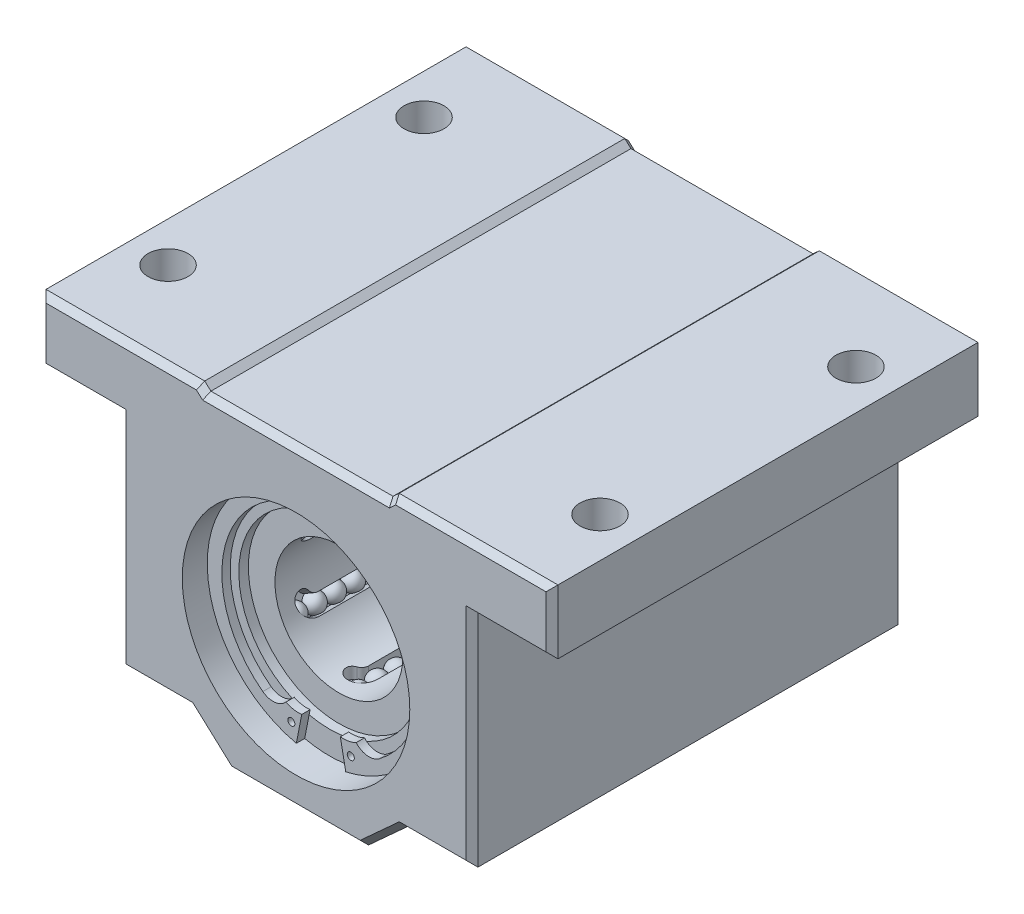
from build123d import *

# Parameters (mm, degrees)
EXTRUDE1_DEPTH          = 21.43125
SKETCH2_R               = 11.288888889
CUT_EXTRUDE1_DEPTH      = 3.31075862
SKETCH3_R               = 0.352777778
EXTRUDE2_DEPTH          = 0.827689654
SKETCH4_R               = 8.98525
CUT_EXTRUDE2_DEPTH      = 0.945931034
SKETCH5_R               = 6.35
CUT_EXTRUDE3_DEPTH      = 49.862912495
CUT_EXTRUDE4_REACH      = 39.542
CUT_EXTRUDE4_END_RADIUS = 7.478888889
CIRPATTERN1_COUNT       = 6
LPATTERN1_COUNT         = 9
LPATTERN1_PITCH         = 1.905
CIRPATTERN2_COUNT       = 6
CHAMFER1_SIZE           = 0.591206894
SKETCH13_R              = 1.984375
CUT_EXTRUDE6_DEPTH      = 6.35


with BuildPart() as part:
    # Sketch1 → Extrude1 (new, symmetric)
    with BuildSketch(Plane.XY):
        Polygon((-25.4, 15.875), (-9.652, 15.875), (-9.03605, 15.310555556), (9.03605, 15.310555556), (9.652, 15.875), (25.4, 15.875), (25.4, 9.525), (17.4625, 9.525), (17.4625, -12.347222222), (10.4775, -12.347222222), (6.604608895, -15.875), (-6.604608895, -15.875), (-10.4775, -12.347222222), (-17.4625, -12.347222222), (-17.4625, 9.525), (-25.4, 9.525), align=None)
    extrude(amount=EXTRUDE1_DEPTH, both=True)

    # Sketch2 → Cut-Extrude1 (cut)
    with BuildSketch(Plane.XY.offset(21.43125)):
        with Locations((0, -1.5875)):
            Circle(SKETCH2_R)
    cut_extrude1 = extrude(amount=-CUT_EXTRUDE1_DEPTH, mode=Mode.SUBTRACT)

    # Sketch3 → Extrude2 (add)
    with BuildSketch(Plane.XY.offset(18.12049138)):
        with BuildLine():
            Line((-1.91681812, -9.861174357), (-2.450589961, -12.607192427))
            ThreePointArc((-2.450589961, -12.607192427), (0, 9.701388889), (2.450589961, -12.607192427))
            Line((2.450589961, -12.607192427), (1.91681812, -9.861174357))
            ThreePointArc((1.91681812, -9.861174357), (2.721690888, -9.833278855), (3.485913703, -9.579188668))
            ThreePointArc((3.485913703, -9.579188668), (4.584638215, -10.150633104), (5.778499999, -9.821333333))
            ThreePointArc((5.778499999, -9.821333333), (9.370152648, 1.368526587), (0, 8.461704518))
            ThreePointArc((0, 8.461704518), (-9.370152648, 1.368526587), (-5.778499999, -9.821333333))
            ThreePointArc((-5.778499999, -9.821333333), (-4.584638215, -10.150633104), (-3.485913703, -9.579188668))
            ThreePointArc((-3.485913703, -9.579188668), (-2.721690888, -9.833278855), (-1.91681812, -9.861174357))
        make_face()
        with Locations((-2.951219351, -11.014100562)):
            Circle(SKETCH3_R, mode=Mode.SUBTRACT)
        with Locations(Location((2.951219351, -11.014100562, 0), (0, 0, 180))):
            Circle(SKETCH3_R, mode=Mode.SUBTRACT)
    extrude2 = extrude(amount=EXTRUDE2_DEPTH)

    # Sketch4 → Cut-Extrude2 (cut)
    with BuildSketch(Plane.XY.offset(18.12049138)):
        with Locations((0, -1.5875)):
            Circle(SKETCH4_R)
    cut_extrude2 = extrude(amount=-CUT_EXTRUDE2_DEPTH, mode=Mode.SUBTRACT)

    # Mirror1: Cut-Extrude1, Extrude2, Cut-Extrude2 across plane
    add(cut_extrude1.mirror(Plane.XY), mode=Mode.SUBTRACT)
    add(extrude2.mirror(Plane.XY))
    add(cut_extrude2.mirror(Plane.XY), mode=Mode.SUBTRACT)

    # Sketch5 → Cut-Extrude3 (cut, through all)
    with BuildSketch(Plane.XY.offset(17.174560346)):
        with Locations((0, -1.5875)):
            Circle(SKETCH5_R)
    extrude(amount=-CUT_EXTRUDE3_DEPTH, mode=Mode.SUBTRACT)

    # Cut-Extrude4: up to this cylinder (the profile starts inside it)
    cut_extrude4_end = Plane(origin=(0, -1.5875, 0), z_dir=(0, 0, 1)) * Cylinder(CUT_EXTRUDE4_END_RADIUS, 95.041777778, mode=Mode.PRIVATE)
    # Sketch8 → Cut-Extrude4 (cut, up to the surface)
    with BuildSketch(Plane(origin=(0, -1.5875, 0), x_dir=(-1, 0, 0), z_dir=(0, 1, 0)), mode=Mode.PRIVATE) as cut_extrude4_sk1:
        with BuildLine():
            Line((-0.803275, -14.041163793), (-0.803275, 14.041163793))
            ThreePointArc((-0.803275, 14.041163793), (-0.332727399, 15.177166193), (0.803275, 15.647713793))
            ThreePointArc((0.803275, 15.647713793), (1.576603655, 15.061725508), (1.221647396, 14.158716354))
            ThreePointArc((1.221647396, 14.158716354), (0.915018646, 13.840736557), (0.803275, 13.413365876))
            Line((0.803275, 13.413365876), (0.803275, -13.413365876))
            ThreePointArc((0.803275, -13.413365876), (0.915018646, -13.840736557), (1.221647396, -14.158716354))
            ThreePointArc((1.221647396, -14.158716354), (1.576603655, -15.061725508), (0.803275, -15.647713793))
            ThreePointArc((0.803275, -15.647713793), (-0.332727399, -15.177166193), (-0.803275, -14.041163793))
        make_face()
    cut_extrude4_tool1 = extrude(cut_extrude4_sk1.sketch, amount=-CUT_EXTRUDE4_REACH, mode=Mode.PRIVATE) & cut_extrude4_end
    cut_extrude4 = cut_extrude4_tool1.solids().sort_by_distance((-0.056828, -1.5875, 0))[0]
    add(cut_extrude4, mode=Mode.SUBTRACT)

    # CirPattern1: Cut-Extrude4 ×6 about axis
    cirpattern1_axis = Axis((0, -1.5875, 0), (0, 0, 1))
    for i in range(1, CIRPATTERN1_COUNT):
        add(cut_extrude4.rotate(cirpattern1_axis, i * 360 / CIRPATTERN1_COUNT), mode=Mode.SUBTRACT)

    # Sketch10 → Revolve2 (revolve)
    with BuildSketch(Plane.XY):
        with BuildLine():
            Line((-0.948795833, -8.886295833), (0.948795833, -8.886295833))
            ThreePointArc((0.948795833, -8.886295833), (0, -7.9375), (-0.948795833, -8.886295833))
        make_face()
    revolve2 = revolve(axis=Axis((-0.948795833, -8.886295833, 0), (1, 0, 0)))

    # LPattern1: Revolve2 ×9
    with Locations(*[(0, 0, i * LPATTERN1_PITCH) for i in range(1, LPATTERN1_COUNT)]):
        add(revolve2)

    # Mirror2: Revolve2 across plane
    add(revolve2.mirror(Plane.XY))

    # Mirror2 copy 1 sketch → Mirror2 copy 1 (revolve)
    with BuildSketch(Plane(origin=(0, 0, -1.905), x_dir=(1, 0, 0), z_dir=(0, 0, -1))):
        with BuildLine():
            Line((-0.948795833, 8.886295833), (0.948795833, 8.886295833))
            ThreePointArc((0.948795833, 8.886295833), (0, 7.9375), (-0.948795833, 8.886295833))
        make_face()
    revolve(axis=Axis((-0.948795833, -8.886295833, -1.905), (-1, 0, 0)))

    # Mirror2 copy 2 sketch → Mirror2 copy 2 (revolve)
    with BuildSketch(Plane(origin=(0, 0, -3.81), x_dir=(1, 0, 0), z_dir=(0, 0, -1))):
        with BuildLine():
            Line((-0.948795833, 8.886295833), (0.948795833, 8.886295833))
            ThreePointArc((0.948795833, 8.886295833), (0, 7.9375), (-0.948795833, 8.886295833))
        make_face()
    revolve(axis=Axis((-0.948795833, -8.886295833, -3.81), (-1, 0, 0)))

    # Mirror2 copy 3 sketch → Mirror2 copy 3 (revolve)
    with BuildSketch(Plane(origin=(0, 0, -5.715), x_dir=(1, 0, 0), z_dir=(0, 0, -1))):
        with BuildLine():
            Line((-0.948795833, 8.886295833), (0.948795833, 8.886295833))
            ThreePointArc((0.948795833, 8.886295833), (0, 7.9375), (-0.948795833, 8.886295833))
        make_face()
    revolve(axis=Axis((-0.948795833, -8.886295833, -5.715), (-1, 0, 0)))

    # Mirror2 copy 4 sketch → Mirror2 copy 4 (revolve)
    with BuildSketch(Plane(origin=(0, 0, -7.62), x_dir=(1, 0, 0), z_dir=(0, 0, -1))):
        with BuildLine():
            Line((-0.948795833, 8.886295833), (0.948795833, 8.886295833))
            ThreePointArc((0.948795833, 8.886295833), (0, 7.9375), (-0.948795833, 8.886295833))
        make_face()
    revolve(axis=Axis((-0.948795833, -8.886295833, -7.62), (-1, 0, 0)))

    # Mirror2 copy 5 sketch → Mirror2 copy 5 (revolve)
    with BuildSketch(Plane(origin=(0, 0, -9.525), x_dir=(1, 0, 0), z_dir=(0, 0, -1))):
        with BuildLine():
            Line((-0.948795833, 8.886295833), (0.948795833, 8.886295833))
            ThreePointArc((0.948795833, 8.886295833), (0, 7.9375), (-0.948795833, 8.886295833))
        make_face()
    revolve(axis=Axis((-0.948795833, -8.886295833, -9.525), (-1, 0, 0)))

    # Mirror2 copy 6 sketch → Mirror2 copy 6 (revolve)
    with BuildSketch(Plane(origin=(0, 0, -11.43), x_dir=(1, 0, 0), z_dir=(0, 0, -1))):
        with BuildLine():
            Line((-0.948795833, 8.886295833), (0.948795833, 8.886295833))
            ThreePointArc((0.948795833, 8.886295833), (0, 7.9375), (-0.948795833, 8.886295833))
        make_face()
    revolve(axis=Axis((-0.948795833, -8.886295833, -11.43), (-1, 0, 0)))

    # Mirror2 copy 7 sketch → Mirror2 copy 7 (revolve)
    with BuildSketch(Plane(origin=(0, 0, -13.335), x_dir=(1, 0, 0), z_dir=(0, 0, -1))):
        with BuildLine():
            Line((-0.948795833, 8.886295833), (0.948795833, 8.886295833))
            ThreePointArc((0.948795833, 8.886295833), (0, 7.9375), (-0.948795833, 8.886295833))
        make_face()
    revolve(axis=Axis((-0.948795833, -8.886295833, -13.335), (-1, 0, 0)))

    # Mirror2 copy 8 sketch → Mirror2 copy 8 (revolve)
    with BuildSketch(Plane(origin=(0, 0, -15.24), x_dir=(1, 0, 0), z_dir=(0, 0, -1))):
        with BuildLine():
            Line((-0.948795833, 8.886295833), (0.948795833, 8.886295833))
            ThreePointArc((0.948795833, 8.886295833), (0, 7.9375), (-0.948795833, 8.886295833))
        make_face()
    revolve(axis=Axis((-0.948795833, -8.886295833, -15.24), (-1, 0, 0)))

    # CirPattern2: Revolve2 ×6 about axis
    cirpattern2_axis = Axis((0, -1.5875, 0), (0, 0, 1))
    for i in range(1, CIRPATTERN2_COUNT):
        add(revolve2.rotate(cirpattern2_axis, i * 360 / CIRPATTERN2_COUNT))

    # CirPattern2 copy 1 sketch → CirPattern2 copy 1 (revolve)
    with BuildSketch(Plane(origin=(-1.374815329, -0.79375, 1.905), x_dir=(0.5000000000000001, 0.8660254037844386, 0), z_dir=(0, 0, 1))):
        with BuildLine():
            Line((-0.948795833, -8.886295833), (0.948795833, -8.886295833))
            ThreePointArc((0.948795833, -8.886295833), (0, -7.9375), (-0.948795833, -8.886295833))
        make_face()
    revolve(axis=Axis((5.846544692, -6.058579211, 1.905), (0.5000000000000001, 0.8660254037844386, 0)))

    # CirPattern2 copy 2 sketch → CirPattern2 copy 2 (revolve)
    with BuildSketch(Plane(origin=(-1.374815329, -2.38125, 1.905), x_dir=(-0.4999999999999998, 0.8660254037844387, 0), z_dir=(0, 0, 1))):
        with BuildLine():
            Line((-0.948795833, -8.886295833), (0.948795833, -8.886295833))
            ThreePointArc((0.948795833, -8.886295833), (0, -7.9375), (-0.948795833, -8.886295833))
        make_face()
    revolve(axis=Axis((6.795340526, 1.240216622, 1.905), (-0.4999999999999998, 0.8660254037844387, 0)))

    # CirPattern2 copy 3 sketch → CirPattern2 copy 3 (revolve)
    with BuildSketch(Plane(origin=(0, -3.175, 1.905), x_dir=(-1, 0, 0), z_dir=(0, 0, 1))):
        with BuildLine():
            Line((-0.948795833, -8.886295833), (0.948795833, -8.886295833))
            ThreePointArc((0.948795833, -8.886295833), (0, -7.9375), (-0.948795833, -8.886295833))
        make_face()
    revolve(axis=Axis((0.948795833, 5.711295833, 1.905), (-1, 0, 0)))

    # CirPattern2 copy 4 sketch → CirPattern2 copy 4 (revolve)
    with BuildSketch(Plane(origin=(1.374815329, -2.38125, 1.905), x_dir=(-0.5000000000000004, -0.8660254037844384, 0), z_dir=(0, 0, 1))):
        with BuildLine():
            Line((-0.948795833, -8.886295833), (0.948795833, -8.886295833))
            ThreePointArc((0.948795833, -8.886295833), (0, -7.9375), (-0.948795833, -8.886295833))
        make_face()
    revolve(axis=Axis((-5.846544692, 2.883579211, 1.905), (-0.5000000000000004, -0.8660254037844384, 0)))

    # CirPattern2 copy 5 sketch → CirPattern2 copy 5 (revolve)
    with BuildSketch(Plane(origin=(1.374815329, -0.79375, 1.905), x_dir=(0.5000000000000001, -0.8660254037844386, 0), z_dir=(0, 0, 1))):
        with BuildLine():
            Line((-0.948795833, -8.886295833), (0.948795833, -8.886295833))
            ThreePointArc((0.948795833, -8.886295833), (0, -7.9375), (-0.948795833, -8.886295833))
        make_face()
    revolve(axis=Axis((-6.795340526, -4.415216622, 1.905), (0.5000000000000001, -0.8660254037844386, 0)))

    # CirPattern2 copy 6 sketch → CirPattern2 copy 6 (revolve)
    with BuildSketch(Plane(origin=(-1.374815329, -0.79375, 3.81), x_dir=(0.5000000000000001, 0.8660254037844386, 0), z_dir=(0, 0, 1))):
        with BuildLine():
            Line((-0.948795833, -8.886295833), (0.948795833, -8.886295833))
            ThreePointArc((0.948795833, -8.886295833), (0, -7.9375), (-0.948795833, -8.886295833))
        make_face()
    revolve(axis=Axis((5.846544692, -6.058579211, 3.81), (0.5000000000000001, 0.8660254037844386, 0)))

    # CirPattern2 copy 7 sketch → CirPattern2 copy 7 (revolve)
    with BuildSketch(Plane(origin=(-1.374815329, -2.38125, 3.81), x_dir=(-0.4999999999999998, 0.8660254037844387, 0), z_dir=(0, 0, 1))):
        with BuildLine():
            Line((-0.948795833, -8.886295833), (0.948795833, -8.886295833))
            ThreePointArc((0.948795833, -8.886295833), (0, -7.9375), (-0.948795833, -8.886295833))
        make_face()
    revolve(axis=Axis((6.795340526, 1.240216622, 3.81), (-0.4999999999999998, 0.8660254037844387, 0)))

    # CirPattern2 copy 8 sketch → CirPattern2 copy 8 (revolve)
    with BuildSketch(Plane(origin=(0, -3.175, 3.81), x_dir=(-1, 0, 0), z_dir=(0, 0, 1))):
        with BuildLine():
            Line((-0.948795833, -8.886295833), (0.948795833, -8.886295833))
            ThreePointArc((0.948795833, -8.886295833), (0, -7.9375), (-0.948795833, -8.886295833))
        make_face()
    revolve(axis=Axis((0.948795833, 5.711295833, 3.81), (-1, 0, 0)))

    # CirPattern2 copy 9 sketch → CirPattern2 copy 9 (revolve)
    with BuildSketch(Plane(origin=(1.374815329, -2.38125, 3.81), x_dir=(-0.5000000000000004, -0.8660254037844384, 0), z_dir=(0, 0, 1))):
        with BuildLine():
            Line((-0.948795833, -8.886295833), (0.948795833, -8.886295833))
            ThreePointArc((0.948795833, -8.886295833), (0, -7.9375), (-0.948795833, -8.886295833))
        make_face()
    revolve(axis=Axis((-5.846544692, 2.883579211, 3.81), (-0.5000000000000004, -0.8660254037844384, 0)))

    # CirPattern2 copy 10 sketch → CirPattern2 copy 10 (revolve)
    with BuildSketch(Plane(origin=(1.374815329, -0.79375, 3.81), x_dir=(0.5000000000000001, -0.8660254037844386, 0), z_dir=(0, 0, 1))):
        with BuildLine():
            Line((-0.948795833, -8.886295833), (0.948795833, -8.886295833))
            ThreePointArc((0.948795833, -8.886295833), (0, -7.9375), (-0.948795833, -8.886295833))
        make_face()
    revolve(axis=Axis((-6.795340526, -4.415216622, 3.81), (0.5000000000000001, -0.8660254037844386, 0)))

    # CirPattern2 copy 11 sketch → CirPattern2 copy 11 (revolve)
    with BuildSketch(Plane(origin=(-1.374815329, -0.79375, 5.715), x_dir=(0.5000000000000001, 0.8660254037844386, 0), z_dir=(0, 0, 1))):
        with BuildLine():
            Line((-0.948795833, -8.886295833), (0.948795833, -8.886295833))
            ThreePointArc((0.948795833, -8.886295833), (0, -7.9375), (-0.948795833, -8.886295833))
        make_face()
    revolve(axis=Axis((5.846544692, -6.058579211, 5.715), (0.5000000000000001, 0.8660254037844386, 0)))

    # CirPattern2 copy 12 sketch → CirPattern2 copy 12 (revolve)
    with BuildSketch(Plane(origin=(-1.374815329, -2.38125, 5.715), x_dir=(-0.4999999999999998, 0.8660254037844387, 0), z_dir=(0, 0, 1))):
        with BuildLine():
            Line((-0.948795833, -8.886295833), (0.948795833, -8.886295833))
            ThreePointArc((0.948795833, -8.886295833), (0, -7.9375), (-0.948795833, -8.886295833))
        make_face()
    revolve(axis=Axis((6.795340526, 1.240216622, 5.715), (-0.4999999999999998, 0.8660254037844387, 0)))

    # CirPattern2 copy 13 sketch → CirPattern2 copy 13 (revolve)
    with BuildSketch(Plane(origin=(0, -3.175, 5.715), x_dir=(-1, 0, 0), z_dir=(0, 0, 1))):
        with BuildLine():
            Line((-0.948795833, -8.886295833), (0.948795833, -8.886295833))
            ThreePointArc((0.948795833, -8.886295833), (0, -7.9375), (-0.948795833, -8.886295833))
        make_face()
    revolve(axis=Axis((0.948795833, 5.711295833, 5.715), (-1, 0, 0)))

    # CirPattern2 copy 14 sketch → CirPattern2 copy 14 (revolve)
    with BuildSketch(Plane(origin=(1.374815329, -2.38125, 5.715), x_dir=(-0.5000000000000004, -0.8660254037844384, 0), z_dir=(0, 0, 1))):
        with BuildLine():
            Line((-0.948795833, -8.886295833), (0.948795833, -8.886295833))
            ThreePointArc((0.948795833, -8.886295833), (0, -7.9375), (-0.948795833, -8.886295833))
        make_face()
    revolve(axis=Axis((-5.846544692, 2.883579211, 5.715), (-0.5000000000000004, -0.8660254037844384, 0)))

    # CirPattern2 copy 15 sketch → CirPattern2 copy 15 (revolve)
    with BuildSketch(Plane(origin=(1.374815329, -0.79375, 5.715), x_dir=(0.5000000000000001, -0.8660254037844386, 0), z_dir=(0, 0, 1))):
        with BuildLine():
            Line((-0.948795833, -8.886295833), (0.948795833, -8.886295833))
            ThreePointArc((0.948795833, -8.886295833), (0, -7.9375), (-0.948795833, -8.886295833))
        make_face()
    revolve(axis=Axis((-6.795340526, -4.415216622, 5.715), (0.5000000000000001, -0.8660254037844386, 0)))

    # CirPattern2 copy 16 sketch → CirPattern2 copy 16 (revolve)
    with BuildSketch(Plane(origin=(-1.374815329, -0.79375, 7.62), x_dir=(0.5000000000000001, 0.8660254037844386, 0), z_dir=(0, 0, 1))):
        with BuildLine():
            Line((-0.948795833, -8.886295833), (0.948795833, -8.886295833))
            ThreePointArc((0.948795833, -8.886295833), (0, -7.9375), (-0.948795833, -8.886295833))
        make_face()
    revolve(axis=Axis((5.846544692, -6.058579211, 7.62), (0.5000000000000001, 0.8660254037844386, 0)))

    # CirPattern2 copy 17 sketch → CirPattern2 copy 17 (revolve)
    with BuildSketch(Plane(origin=(-1.374815329, -2.38125, 7.62), x_dir=(-0.4999999999999998, 0.8660254037844387, 0), z_dir=(0, 0, 1))):
        with BuildLine():
            Line((-0.948795833, -8.886295833), (0.948795833, -8.886295833))
            ThreePointArc((0.948795833, -8.886295833), (0, -7.9375), (-0.948795833, -8.886295833))
        make_face()
    revolve(axis=Axis((6.795340526, 1.240216622, 7.62), (-0.4999999999999998, 0.8660254037844387, 0)))

    # CirPattern2 copy 18 sketch → CirPattern2 copy 18 (revolve)
    with BuildSketch(Plane(origin=(0, -3.175, 7.62), x_dir=(-1, 0, 0), z_dir=(0, 0, 1))):
        with BuildLine():
            Line((-0.948795833, -8.886295833), (0.948795833, -8.886295833))
            ThreePointArc((0.948795833, -8.886295833), (0, -7.9375), (-0.948795833, -8.886295833))
        make_face()
    revolve(axis=Axis((0.948795833, 5.711295833, 7.62), (-1, 0, 0)))

    # CirPattern2 copy 19 sketch → CirPattern2 copy 19 (revolve)
    with BuildSketch(Plane(origin=(1.374815329, -2.38125, 7.62), x_dir=(-0.5000000000000004, -0.8660254037844384, 0), z_dir=(0, 0, 1))):
        with BuildLine():
            Line((-0.948795833, -8.886295833), (0.948795833, -8.886295833))
            ThreePointArc((0.948795833, -8.886295833), (0, -7.9375), (-0.948795833, -8.886295833))
        make_face()
    revolve(axis=Axis((-5.846544692, 2.883579211, 7.62), (-0.5000000000000004, -0.8660254037844384, 0)))

    # CirPattern2 copy 20 sketch → CirPattern2 copy 20 (revolve)
    with BuildSketch(Plane(origin=(1.374815329, -0.79375, 7.62), x_dir=(0.5000000000000001, -0.8660254037844386, 0), z_dir=(0, 0, 1))):
        with BuildLine():
            Line((-0.948795833, -8.886295833), (0.948795833, -8.886295833))
            ThreePointArc((0.948795833, -8.886295833), (0, -7.9375), (-0.948795833, -8.886295833))
        make_face()
    revolve(axis=Axis((-6.795340526, -4.415216622, 7.62), (0.5000000000000001, -0.8660254037844386, 0)))

    # CirPattern2 copy 21 sketch → CirPattern2 copy 21 (revolve)
    with BuildSketch(Plane(origin=(-1.374815329, -0.79375, 9.525), x_dir=(0.5000000000000001, 0.8660254037844386, 0), z_dir=(0, 0, 1))):
        with BuildLine():
            Line((-0.948795833, -8.886295833), (0.948795833, -8.886295833))
            ThreePointArc((0.948795833, -8.886295833), (0, -7.9375), (-0.948795833, -8.886295833))
        make_face()
    revolve(axis=Axis((5.846544692, -6.058579211, 9.525), (0.5000000000000001, 0.8660254037844386, 0)))

    # CirPattern2 copy 22 sketch → CirPattern2 copy 22 (revolve)
    with BuildSketch(Plane(origin=(-1.374815329, -2.38125, 9.525), x_dir=(-0.4999999999999998, 0.8660254037844387, 0), z_dir=(0, 0, 1))):
        with BuildLine():
            Line((-0.948795833, -8.886295833), (0.948795833, -8.886295833))
            ThreePointArc((0.948795833, -8.886295833), (0, -7.9375), (-0.948795833, -8.886295833))
        make_face()
    revolve(axis=Axis((6.795340526, 1.240216622, 9.525), (-0.4999999999999998, 0.8660254037844387, 0)))

    # CirPattern2 copy 23 sketch → CirPattern2 copy 23 (revolve)
    with BuildSketch(Plane(origin=(0, -3.175, 9.525), x_dir=(-1, 0, 0), z_dir=(0, 0, 1))):
        with BuildLine():
            Line((-0.948795833, -8.886295833), (0.948795833, -8.886295833))
            ThreePointArc((0.948795833, -8.886295833), (0, -7.9375), (-0.948795833, -8.886295833))
        make_face()
    revolve(axis=Axis((0.948795833, 5.711295833, 9.525), (-1, 0, 0)))

    # CirPattern2 copy 24 sketch → CirPattern2 copy 24 (revolve)
    with BuildSketch(Plane(origin=(1.374815329, -2.38125, 9.525), x_dir=(-0.5000000000000004, -0.8660254037844384, 0), z_dir=(0, 0, 1))):
        with BuildLine():
            Line((-0.948795833, -8.886295833), (0.948795833, -8.886295833))
            ThreePointArc((0.948795833, -8.886295833), (0, -7.9375), (-0.948795833, -8.886295833))
        make_face()
    revolve(axis=Axis((-5.846544692, 2.883579211, 9.525), (-0.5000000000000004, -0.8660254037844384, 0)))

    # CirPattern2 copy 25 sketch → CirPattern2 copy 25 (revolve)
    with BuildSketch(Plane(origin=(1.374815329, -0.79375, 9.525), x_dir=(0.5000000000000001, -0.8660254037844386, 0), z_dir=(0, 0, 1))):
        with BuildLine():
            Line((-0.948795833, -8.886295833), (0.948795833, -8.886295833))
            ThreePointArc((0.948795833, -8.886295833), (0, -7.9375), (-0.948795833, -8.886295833))
        make_face()
    revolve(axis=Axis((-6.795340526, -4.415216622, 9.525), (0.5000000000000001, -0.8660254037844386, 0)))

    # CirPattern2 copy 26 sketch → CirPattern2 copy 26 (revolve)
    with BuildSketch(Plane(origin=(-1.374815329, -0.79375, 11.43), x_dir=(0.5000000000000001, 0.8660254037844386, 0), z_dir=(0, 0, 1))):
        with BuildLine():
            Line((-0.948795833, -8.886295833), (0.948795833, -8.886295833))
            ThreePointArc((0.948795833, -8.886295833), (0, -7.9375), (-0.948795833, -8.886295833))
        make_face()
    revolve(axis=Axis((5.846544692, -6.058579211, 11.43), (0.5000000000000001, 0.8660254037844386, 0)))

    # CirPattern2 copy 27 sketch → CirPattern2 copy 27 (revolve)
    with BuildSketch(Plane(origin=(-1.374815329, -2.38125, 11.43), x_dir=(-0.4999999999999998, 0.8660254037844387, 0), z_dir=(0, 0, 1))):
        with BuildLine():
            Line((-0.948795833, -8.886295833), (0.948795833, -8.886295833))
            ThreePointArc((0.948795833, -8.886295833), (0, -7.9375), (-0.948795833, -8.886295833))
        make_face()
    revolve(axis=Axis((6.795340526, 1.240216622, 11.43), (-0.4999999999999998, 0.8660254037844387, 0)))

    # CirPattern2 copy 28 sketch → CirPattern2 copy 28 (revolve)
    with BuildSketch(Plane(origin=(0, -3.175, 11.43), x_dir=(-1, 0, 0), z_dir=(0, 0, 1))):
        with BuildLine():
            Line((-0.948795833, -8.886295833), (0.948795833, -8.886295833))
            ThreePointArc((0.948795833, -8.886295833), (0, -7.9375), (-0.948795833, -8.886295833))
        make_face()
    revolve(axis=Axis((0.948795833, 5.711295833, 11.43), (-1, 0, 0)))

    # CirPattern2 copy 29 sketch → CirPattern2 copy 29 (revolve)
    with BuildSketch(Plane(origin=(1.374815329, -2.38125, 11.43), x_dir=(-0.5000000000000004, -0.8660254037844384, 0), z_dir=(0, 0, 1))):
        with BuildLine():
            Line((-0.948795833, -8.886295833), (0.948795833, -8.886295833))
            ThreePointArc((0.948795833, -8.886295833), (0, -7.9375), (-0.948795833, -8.886295833))
        make_face()
    revolve(axis=Axis((-5.846544692, 2.883579211, 11.43), (-0.5000000000000004, -0.8660254037844384, 0)))

    # CirPattern2 copy 30 sketch → CirPattern2 copy 30 (revolve)
    with BuildSketch(Plane(origin=(1.374815329, -0.79375, 11.43), x_dir=(0.5000000000000001, -0.8660254037844386, 0), z_dir=(0, 0, 1))):
        with BuildLine():
            Line((-0.948795833, -8.886295833), (0.948795833, -8.886295833))
            ThreePointArc((0.948795833, -8.886295833), (0, -7.9375), (-0.948795833, -8.886295833))
        make_face()
    revolve(axis=Axis((-6.795340526, -4.415216622, 11.43), (0.5000000000000001, -0.8660254037844386, 0)))

    # CirPattern2 copy 31 sketch → CirPattern2 copy 31 (revolve)
    with BuildSketch(Plane(origin=(-1.374815329, -0.79375, 13.335), x_dir=(0.5000000000000001, 0.8660254037844386, 0), z_dir=(0, 0, 1))):
        with BuildLine():
            Line((-0.948795833, -8.886295833), (0.948795833, -8.886295833))
            ThreePointArc((0.948795833, -8.886295833), (0, -7.9375), (-0.948795833, -8.886295833))
        make_face()
    revolve(axis=Axis((5.846544692, -6.058579211, 13.335), (0.5000000000000001, 0.8660254037844386, 0)))

    # CirPattern2 copy 32 sketch → CirPattern2 copy 32 (revolve)
    with BuildSketch(Plane(origin=(-1.374815329, -2.38125, 13.335), x_dir=(-0.4999999999999998, 0.8660254037844387, 0), z_dir=(0, 0, 1))):
        with BuildLine():
            Line((-0.948795833, -8.886295833), (0.948795833, -8.886295833))
            ThreePointArc((0.948795833, -8.886295833), (0, -7.9375), (-0.948795833, -8.886295833))
        make_face()
    revolve(axis=Axis((6.795340526, 1.240216622, 13.335), (-0.4999999999999998, 0.8660254037844387, 0)))

    # CirPattern2 copy 33 sketch → CirPattern2 copy 33 (revolve)
    with BuildSketch(Plane(origin=(0, -3.175, 13.335), x_dir=(-1, 0, 0), z_dir=(0, 0, 1))):
        with BuildLine():
            Line((-0.948795833, -8.886295833), (0.948795833, -8.886295833))
            ThreePointArc((0.948795833, -8.886295833), (0, -7.9375), (-0.948795833, -8.886295833))
        make_face()
    revolve(axis=Axis((0.948795833, 5.711295833, 13.335), (-1, 0, 0)))

    # CirPattern2 copy 34 sketch → CirPattern2 copy 34 (revolve)
    with BuildSketch(Plane(origin=(1.374815329, -2.38125, 13.335), x_dir=(-0.5000000000000004, -0.8660254037844384, 0), z_dir=(0, 0, 1))):
        with BuildLine():
            Line((-0.948795833, -8.886295833), (0.948795833, -8.886295833))
            ThreePointArc((0.948795833, -8.886295833), (0, -7.9375), (-0.948795833, -8.886295833))
        make_face()
    revolve(axis=Axis((-5.846544692, 2.883579211, 13.335), (-0.5000000000000004, -0.8660254037844384, 0)))

    # CirPattern2 copy 35 sketch → CirPattern2 copy 35 (revolve)
    with BuildSketch(Plane(origin=(1.374815329, -0.79375, 13.335), x_dir=(0.5000000000000001, -0.8660254037844386, 0), z_dir=(0, 0, 1))):
        with BuildLine():
            Line((-0.948795833, -8.886295833), (0.948795833, -8.886295833))
            ThreePointArc((0.948795833, -8.886295833), (0, -7.9375), (-0.948795833, -8.886295833))
        make_face()
    revolve(axis=Axis((-6.795340526, -4.415216622, 13.335), (0.5000000000000001, -0.8660254037844386, 0)))

    # CirPattern2 copy 36 sketch → CirPattern2 copy 36 (revolve)
    with BuildSketch(Plane(origin=(-1.374815329, -0.79375, 15.24), x_dir=(0.5000000000000001, 0.8660254037844386, 0), z_dir=(0, 0, 1))):
        with BuildLine():
            Line((-0.948795833, -8.886295833), (0.948795833, -8.886295833))
            ThreePointArc((0.948795833, -8.886295833), (0, -7.9375), (-0.948795833, -8.886295833))
        make_face()
    revolve(axis=Axis((5.846544692, -6.058579211, 15.24), (0.5000000000000001, 0.8660254037844386, 0)))

    # CirPattern2 copy 37 sketch → CirPattern2 copy 37 (revolve)
    with BuildSketch(Plane(origin=(-1.374815329, -2.38125, 15.24), x_dir=(-0.4999999999999998, 0.8660254037844387, 0), z_dir=(0, 0, 1))):
        with BuildLine():
            Line((-0.948795833, -8.886295833), (0.948795833, -8.886295833))
            ThreePointArc((0.948795833, -8.886295833), (0, -7.9375), (-0.948795833, -8.886295833))
        make_face()
    revolve(axis=Axis((6.795340526, 1.240216622, 15.24), (-0.4999999999999998, 0.8660254037844387, 0)))

    # CirPattern2 copy 38 sketch → CirPattern2 copy 38 (revolve)
    with BuildSketch(Plane(origin=(0, -3.175, 15.24), x_dir=(-1, 0, 0), z_dir=(0, 0, 1))):
        with BuildLine():
            Line((-0.948795833, -8.886295833), (0.948795833, -8.886295833))
            ThreePointArc((0.948795833, -8.886295833), (0, -7.9375), (-0.948795833, -8.886295833))
        make_face()
    revolve(axis=Axis((0.948795833, 5.711295833, 15.24), (-1, 0, 0)))

    # CirPattern2 copy 39 sketch → CirPattern2 copy 39 (revolve)
    with BuildSketch(Plane(origin=(1.374815329, -2.38125, 15.24), x_dir=(-0.5000000000000004, -0.8660254037844384, 0), z_dir=(0, 0, 1))):
        with BuildLine():
            Line((-0.948795833, -8.886295833), (0.948795833, -8.886295833))
            ThreePointArc((0.948795833, -8.886295833), (0, -7.9375), (-0.948795833, -8.886295833))
        make_face()
    revolve(axis=Axis((-5.846544692, 2.883579211, 15.24), (-0.5000000000000004, -0.8660254037844384, 0)))

    # CirPattern2 copy 40 sketch → CirPattern2 copy 40 (revolve)
    with BuildSketch(Plane(origin=(1.374815329, -0.79375, 15.24), x_dir=(0.5000000000000001, -0.8660254037844386, 0), z_dir=(0, 0, 1))):
        with BuildLine():
            Line((-0.948795833, -8.886295833), (0.948795833, -8.886295833))
            ThreePointArc((0.948795833, -8.886295833), (0, -7.9375), (-0.948795833, -8.886295833))
        make_face()
    revolve(axis=Axis((-6.795340526, -4.415216622, 15.24), (0.5000000000000001, -0.8660254037844386, 0)))

    # CirPattern2 copy 41 sketch → CirPattern2 copy 41 (revolve)
    with BuildSketch(Plane(origin=(-1.374815329, -0.79375, 0), x_dir=(0.5000000000000001, 0.8660254037844386, 0), z_dir=(0, 0, -1))):
        with BuildLine():
            Line((-0.948795833, 8.886295833), (0.948795833, 8.886295833))
            ThreePointArc((0.948795833, 8.886295833), (0, 7.9375), (-0.948795833, 8.886295833))
        make_face()
    revolve(axis=Axis((5.846544692, -6.058579211, 0), (-0.5000000000000001, -0.8660254037844386, 0)))

    # CirPattern2 copy 42 sketch → CirPattern2 copy 42 (revolve)
    with BuildSketch(Plane(origin=(-1.374815329, -2.38125, 0), x_dir=(-0.4999999999999998, 0.8660254037844387, 0), z_dir=(0, 0, -1))):
        with BuildLine():
            Line((-0.948795833, 8.886295833), (0.948795833, 8.886295833))
            ThreePointArc((0.948795833, 8.886295833), (0, 7.9375), (-0.948795833, 8.886295833))
        make_face()
    revolve(axis=Axis((6.795340526, 1.240216622, 0), (0.4999999999999998, -0.8660254037844387, 0)))

    # CirPattern2 copy 43 sketch → CirPattern2 copy 43 (revolve)
    with BuildSketch(Plane(origin=(0, -3.175, 0), x_dir=(-1, 0, 0), z_dir=(0, 0, -1))):
        with BuildLine():
            Line((-0.948795833, 8.886295833), (0.948795833, 8.886295833))
            ThreePointArc((0.948795833, 8.886295833), (0, 7.9375), (-0.948795833, 8.886295833))
        make_face()
    revolve(axis=Axis((0.948795833, 5.711295833, 0), (1, 0, 0)))

    # CirPattern2 copy 44 sketch → CirPattern2 copy 44 (revolve)
    with BuildSketch(Plane(origin=(1.374815329, -2.38125, 0), x_dir=(-0.5000000000000004, -0.8660254037844384, 0), z_dir=(0, 0, -1))):
        with BuildLine():
            Line((-0.948795833, 8.886295833), (0.948795833, 8.886295833))
            ThreePointArc((0.948795833, 8.886295833), (0, 7.9375), (-0.948795833, 8.886295833))
        make_face()
    revolve(axis=Axis((-5.846544692, 2.883579211, 0), (0.5000000000000004, 0.8660254037844384, 0)))

    # CirPattern2 copy 45 sketch → CirPattern2 copy 45 (revolve)
    with BuildSketch(Plane(origin=(1.374815329, -0.79375, 0), x_dir=(0.5000000000000001, -0.8660254037844386, 0), z_dir=(0, 0, -1))):
        with BuildLine():
            Line((-0.948795833, 8.886295833), (0.948795833, 8.886295833))
            ThreePointArc((0.948795833, 8.886295833), (0, 7.9375), (-0.948795833, 8.886295833))
        make_face()
    revolve(axis=Axis((-6.795340526, -4.415216622, 0), (-0.5000000000000001, 0.8660254037844386, 0)))

    # CirPattern2 copy 46 sketch → CirPattern2 copy 46 (revolve)
    with BuildSketch(Plane(origin=(-1.374815329, -0.79375, -1.905), x_dir=(0.5000000000000001, 0.8660254037844386, 0), z_dir=(0, 0, -1))):
        with BuildLine():
            Line((-0.948795833, 8.886295833), (0.948795833, 8.886295833))
            ThreePointArc((0.948795833, 8.886295833), (0, 7.9375), (-0.948795833, 8.886295833))
        make_face()
    revolve(axis=Axis((5.846544692, -6.058579211, -1.905), (-0.5000000000000001, -0.8660254037844386, 0)))

    # CirPattern2 copy 47 sketch → CirPattern2 copy 47 (revolve)
    with BuildSketch(Plane(origin=(-1.374815329, -2.38125, -1.905), x_dir=(-0.4999999999999998, 0.8660254037844387, 0), z_dir=(0, 0, -1))):
        with BuildLine():
            Line((-0.948795833, 8.886295833), (0.948795833, 8.886295833))
            ThreePointArc((0.948795833, 8.886295833), (0, 7.9375), (-0.948795833, 8.886295833))
        make_face()
    revolve(axis=Axis((6.795340526, 1.240216622, -1.905), (0.4999999999999998, -0.8660254037844387, 0)))

    # CirPattern2 copy 48 sketch → CirPattern2 copy 48 (revolve)
    with BuildSketch(Plane(origin=(0, -3.175, -1.905), x_dir=(-1, 0, 0), z_dir=(0, 0, -1))):
        with BuildLine():
            Line((-0.948795833, 8.886295833), (0.948795833, 8.886295833))
            ThreePointArc((0.948795833, 8.886295833), (0, 7.9375), (-0.948795833, 8.886295833))
        make_face()
    revolve(axis=Axis((0.948795833, 5.711295833, -1.905), (1, 0, 0)))

    # CirPattern2 copy 49 sketch → CirPattern2 copy 49 (revolve)
    with BuildSketch(Plane(origin=(1.374815329, -2.38125, -1.905), x_dir=(-0.5000000000000004, -0.8660254037844384, 0), z_dir=(0, 0, -1))):
        with BuildLine():
            Line((-0.948795833, 8.886295833), (0.948795833, 8.886295833))
            ThreePointArc((0.948795833, 8.886295833), (0, 7.9375), (-0.948795833, 8.886295833))
        make_face()
    revolve(axis=Axis((-5.846544692, 2.883579211, -1.905), (0.5000000000000004, 0.8660254037844384, 0)))

    # CirPattern2 copy 50 sketch → CirPattern2 copy 50 (revolve)
    with BuildSketch(Plane(origin=(1.374815329, -0.79375, -1.905), x_dir=(0.5000000000000001, -0.8660254037844386, 0), z_dir=(0, 0, -1))):
        with BuildLine():
            Line((-0.948795833, 8.886295833), (0.948795833, 8.886295833))
            ThreePointArc((0.948795833, 8.886295833), (0, 7.9375), (-0.948795833, 8.886295833))
        make_face()
    revolve(axis=Axis((-6.795340526, -4.415216622, -1.905), (-0.5000000000000001, 0.8660254037844386, 0)))

    # CirPattern2 copy 51 sketch → CirPattern2 copy 51 (revolve)
    with BuildSketch(Plane(origin=(-1.374815329, -0.79375, -3.81), x_dir=(0.5000000000000001, 0.8660254037844386, 0), z_dir=(0, 0, -1))):
        with BuildLine():
            Line((-0.948795833, 8.886295833), (0.948795833, 8.886295833))
            ThreePointArc((0.948795833, 8.886295833), (0, 7.9375), (-0.948795833, 8.886295833))
        make_face()
    revolve(axis=Axis((5.846544692, -6.058579211, -3.81), (-0.5000000000000001, -0.8660254037844386, 0)))

    # CirPattern2 copy 52 sketch → CirPattern2 copy 52 (revolve)
    with BuildSketch(Plane(origin=(-1.374815329, -2.38125, -3.81), x_dir=(-0.4999999999999998, 0.8660254037844387, 0), z_dir=(0, 0, -1))):
        with BuildLine():
            Line((-0.948795833, 8.886295833), (0.948795833, 8.886295833))
            ThreePointArc((0.948795833, 8.886295833), (0, 7.9375), (-0.948795833, 8.886295833))
        make_face()
    revolve(axis=Axis((6.795340526, 1.240216622, -3.81), (0.4999999999999998, -0.8660254037844387, 0)))

    # CirPattern2 copy 53 sketch → CirPattern2 copy 53 (revolve)
    with BuildSketch(Plane(origin=(0, -3.175, -3.81), x_dir=(-1, 0, 0), z_dir=(0, 0, -1))):
        with BuildLine():
            Line((-0.948795833, 8.886295833), (0.948795833, 8.886295833))
            ThreePointArc((0.948795833, 8.886295833), (0, 7.9375), (-0.948795833, 8.886295833))
        make_face()
    revolve(axis=Axis((0.948795833, 5.711295833, -3.81), (1, 0, 0)))

    # CirPattern2 copy 54 sketch → CirPattern2 copy 54 (revolve)
    with BuildSketch(Plane(origin=(1.374815329, -2.38125, -3.81), x_dir=(-0.5000000000000004, -0.8660254037844384, 0), z_dir=(0, 0, -1))):
        with BuildLine():
            Line((-0.948795833, 8.886295833), (0.948795833, 8.886295833))
            ThreePointArc((0.948795833, 8.886295833), (0, 7.9375), (-0.948795833, 8.886295833))
        make_face()
    revolve(axis=Axis((-5.846544692, 2.883579211, -3.81), (0.5000000000000004, 0.8660254037844384, 0)))

    # CirPattern2 copy 55 sketch → CirPattern2 copy 55 (revolve)
    with BuildSketch(Plane(origin=(1.374815329, -0.79375, -3.81), x_dir=(0.5000000000000001, -0.8660254037844386, 0), z_dir=(0, 0, -1))):
        with BuildLine():
            Line((-0.948795833, 8.886295833), (0.948795833, 8.886295833))
            ThreePointArc((0.948795833, 8.886295833), (0, 7.9375), (-0.948795833, 8.886295833))
        make_face()
    revolve(axis=Axis((-6.795340526, -4.415216622, -3.81), (-0.5000000000000001, 0.8660254037844386, 0)))

    # CirPattern2 copy 56 sketch → CirPattern2 copy 56 (revolve)
    with BuildSketch(Plane(origin=(-1.374815329, -0.79375, -5.715), x_dir=(0.5000000000000001, 0.8660254037844386, 0), z_dir=(0, 0, -1))):
        with BuildLine():
            Line((-0.948795833, 8.886295833), (0.948795833, 8.886295833))
            ThreePointArc((0.948795833, 8.886295833), (0, 7.9375), (-0.948795833, 8.886295833))
        make_face()
    revolve(axis=Axis((5.846544692, -6.058579211, -5.715), (-0.5000000000000001, -0.8660254037844386, 0)))

    # CirPattern2 copy 57 sketch → CirPattern2 copy 57 (revolve)
    with BuildSketch(Plane(origin=(-1.374815329, -2.38125, -5.715), x_dir=(-0.4999999999999998, 0.8660254037844387, 0), z_dir=(0, 0, -1))):
        with BuildLine():
            Line((-0.948795833, 8.886295833), (0.948795833, 8.886295833))
            ThreePointArc((0.948795833, 8.886295833), (0, 7.9375), (-0.948795833, 8.886295833))
        make_face()
    revolve(axis=Axis((6.795340526, 1.240216622, -5.715), (0.4999999999999998, -0.8660254037844387, 0)))

    # CirPattern2 copy 58 sketch → CirPattern2 copy 58 (revolve)
    with BuildSketch(Plane(origin=(0, -3.175, -5.715), x_dir=(-1, 0, 0), z_dir=(0, 0, -1))):
        with BuildLine():
            Line((-0.948795833, 8.886295833), (0.948795833, 8.886295833))
            ThreePointArc((0.948795833, 8.886295833), (0, 7.9375), (-0.948795833, 8.886295833))
        make_face()
    revolve(axis=Axis((0.948795833, 5.711295833, -5.715), (1, 0, 0)))

    # CirPattern2 copy 59 sketch → CirPattern2 copy 59 (revolve)
    with BuildSketch(Plane(origin=(1.374815329, -2.38125, -5.715), x_dir=(-0.5000000000000004, -0.8660254037844384, 0), z_dir=(0, 0, -1))):
        with BuildLine():
            Line((-0.948795833, 8.886295833), (0.948795833, 8.886295833))
            ThreePointArc((0.948795833, 8.886295833), (0, 7.9375), (-0.948795833, 8.886295833))
        make_face()
    revolve(axis=Axis((-5.846544692, 2.883579211, -5.715), (0.5000000000000004, 0.8660254037844384, 0)))

    # CirPattern2 copy 60 sketch → CirPattern2 copy 60 (revolve)
    with BuildSketch(Plane(origin=(1.374815329, -0.79375, -5.715), x_dir=(0.5000000000000001, -0.8660254037844386, 0), z_dir=(0, 0, -1))):
        with BuildLine():
            Line((-0.948795833, 8.886295833), (0.948795833, 8.886295833))
            ThreePointArc((0.948795833, 8.886295833), (0, 7.9375), (-0.948795833, 8.886295833))
        make_face()
    revolve(axis=Axis((-6.795340526, -4.415216622, -5.715), (-0.5000000000000001, 0.8660254037844386, 0)))

    # CirPattern2 copy 61 sketch → CirPattern2 copy 61 (revolve)
    with BuildSketch(Plane(origin=(-1.374815329, -0.79375, -7.62), x_dir=(0.5000000000000001, 0.8660254037844386, 0), z_dir=(0, 0, -1))):
        with BuildLine():
            Line((-0.948795833, 8.886295833), (0.948795833, 8.886295833))
            ThreePointArc((0.948795833, 8.886295833), (0, 7.9375), (-0.948795833, 8.886295833))
        make_face()
    revolve(axis=Axis((5.846544692, -6.058579211, -7.62), (-0.5000000000000001, -0.8660254037844386, 0)))

    # CirPattern2 copy 62 sketch → CirPattern2 copy 62 (revolve)
    with BuildSketch(Plane(origin=(-1.374815329, -2.38125, -7.62), x_dir=(-0.4999999999999998, 0.8660254037844387, 0), z_dir=(0, 0, -1))):
        with BuildLine():
            Line((-0.948795833, 8.886295833), (0.948795833, 8.886295833))
            ThreePointArc((0.948795833, 8.886295833), (0, 7.9375), (-0.948795833, 8.886295833))
        make_face()
    revolve(axis=Axis((6.795340526, 1.240216622, -7.62), (0.4999999999999998, -0.8660254037844387, 0)))

    # CirPattern2 copy 63 sketch → CirPattern2 copy 63 (revolve)
    with BuildSketch(Plane(origin=(0, -3.175, -7.62), x_dir=(-1, 0, 0), z_dir=(0, 0, -1))):
        with BuildLine():
            Line((-0.948795833, 8.886295833), (0.948795833, 8.886295833))
            ThreePointArc((0.948795833, 8.886295833), (0, 7.9375), (-0.948795833, 8.886295833))
        make_face()
    revolve(axis=Axis((0.948795833, 5.711295833, -7.62), (1, 0, 0)))

    # CirPattern2 copy 64 sketch → CirPattern2 copy 64 (revolve)
    with BuildSketch(Plane(origin=(1.374815329, -2.38125, -7.62), x_dir=(-0.5000000000000004, -0.8660254037844384, 0), z_dir=(0, 0, -1))):
        with BuildLine():
            Line((-0.948795833, 8.886295833), (0.948795833, 8.886295833))
            ThreePointArc((0.948795833, 8.886295833), (0, 7.9375), (-0.948795833, 8.886295833))
        make_face()
    revolve(axis=Axis((-5.846544692, 2.883579211, -7.62), (0.5000000000000004, 0.8660254037844384, 0)))

    # CirPattern2 copy 65 sketch → CirPattern2 copy 65 (revolve)
    with BuildSketch(Plane(origin=(1.374815329, -0.79375, -7.62), x_dir=(0.5000000000000001, -0.8660254037844386, 0), z_dir=(0, 0, -1))):
        with BuildLine():
            Line((-0.948795833, 8.886295833), (0.948795833, 8.886295833))
            ThreePointArc((0.948795833, 8.886295833), (0, 7.9375), (-0.948795833, 8.886295833))
        make_face()
    revolve(axis=Axis((-6.795340526, -4.415216622, -7.62), (-0.5000000000000001, 0.8660254037844386, 0)))

    # CirPattern2 copy 66 sketch → CirPattern2 copy 66 (revolve)
    with BuildSketch(Plane(origin=(-1.374815329, -0.79375, -9.525), x_dir=(0.5000000000000001, 0.8660254037844386, 0), z_dir=(0, 0, -1))):
        with BuildLine():
            Line((-0.948795833, 8.886295833), (0.948795833, 8.886295833))
            ThreePointArc((0.948795833, 8.886295833), (0, 7.9375), (-0.948795833, 8.886295833))
        make_face()
    revolve(axis=Axis((5.846544692, -6.058579211, -9.525), (-0.5000000000000001, -0.8660254037844386, 0)))

    # CirPattern2 copy 67 sketch → CirPattern2 copy 67 (revolve)
    with BuildSketch(Plane(origin=(-1.374815329, -2.38125, -9.525), x_dir=(-0.4999999999999998, 0.8660254037844387, 0), z_dir=(0, 0, -1))):
        with BuildLine():
            Line((-0.948795833, 8.886295833), (0.948795833, 8.886295833))
            ThreePointArc((0.948795833, 8.886295833), (0, 7.9375), (-0.948795833, 8.886295833))
        make_face()
    revolve(axis=Axis((6.795340526, 1.240216622, -9.525), (0.4999999999999998, -0.8660254037844387, 0)))

    # CirPattern2 copy 68 sketch → CirPattern2 copy 68 (revolve)
    with BuildSketch(Plane(origin=(0, -3.175, -9.525), x_dir=(-1, 0, 0), z_dir=(0, 0, -1))):
        with BuildLine():
            Line((-0.948795833, 8.886295833), (0.948795833, 8.886295833))
            ThreePointArc((0.948795833, 8.886295833), (0, 7.9375), (-0.948795833, 8.886295833))
        make_face()
    revolve(axis=Axis((0.948795833, 5.711295833, -9.525), (1, 0, 0)))

    # CirPattern2 copy 69 sketch → CirPattern2 copy 69 (revolve)
    with BuildSketch(Plane(origin=(1.374815329, -2.38125, -9.525), x_dir=(-0.5000000000000004, -0.8660254037844384, 0), z_dir=(0, 0, -1))):
        with BuildLine():
            Line((-0.948795833, 8.886295833), (0.948795833, 8.886295833))
            ThreePointArc((0.948795833, 8.886295833), (0, 7.9375), (-0.948795833, 8.886295833))
        make_face()
    revolve(axis=Axis((-5.846544692, 2.883579211, -9.525), (0.5000000000000004, 0.8660254037844384, 0)))

    # CirPattern2 copy 70 sketch → CirPattern2 copy 70 (revolve)
    with BuildSketch(Plane(origin=(1.374815329, -0.79375, -9.525), x_dir=(0.5000000000000001, -0.8660254037844386, 0), z_dir=(0, 0, -1))):
        with BuildLine():
            Line((-0.948795833, 8.886295833), (0.948795833, 8.886295833))
            ThreePointArc((0.948795833, 8.886295833), (0, 7.9375), (-0.948795833, 8.886295833))
        make_face()
    revolve(axis=Axis((-6.795340526, -4.415216622, -9.525), (-0.5000000000000001, 0.8660254037844386, 0)))

    # CirPattern2 copy 71 sketch → CirPattern2 copy 71 (revolve)
    with BuildSketch(Plane(origin=(-1.374815329, -0.79375, -11.43), x_dir=(0.5000000000000001, 0.8660254037844386, 0), z_dir=(0, 0, -1))):
        with BuildLine():
            Line((-0.948795833, 8.886295833), (0.948795833, 8.886295833))
            ThreePointArc((0.948795833, 8.886295833), (0, 7.9375), (-0.948795833, 8.886295833))
        make_face()
    revolve(axis=Axis((5.846544692, -6.058579211, -11.43), (-0.5000000000000001, -0.8660254037844386, 0)))

    # CirPattern2 copy 72 sketch → CirPattern2 copy 72 (revolve)
    with BuildSketch(Plane(origin=(-1.374815329, -2.38125, -11.43), x_dir=(-0.4999999999999998, 0.8660254037844387, 0), z_dir=(0, 0, -1))):
        with BuildLine():
            Line((-0.948795833, 8.886295833), (0.948795833, 8.886295833))
            ThreePointArc((0.948795833, 8.886295833), (0, 7.9375), (-0.948795833, 8.886295833))
        make_face()
    revolve(axis=Axis((6.795340526, 1.240216622, -11.43), (0.4999999999999998, -0.8660254037844387, 0)))

    # CirPattern2 copy 73 sketch → CirPattern2 copy 73 (revolve)
    with BuildSketch(Plane(origin=(0, -3.175, -11.43), x_dir=(-1, 0, 0), z_dir=(0, 0, -1))):
        with BuildLine():
            Line((-0.948795833, 8.886295833), (0.948795833, 8.886295833))
            ThreePointArc((0.948795833, 8.886295833), (0, 7.9375), (-0.948795833, 8.886295833))
        make_face()
    revolve(axis=Axis((0.948795833, 5.711295833, -11.43), (1, 0, 0)))

    # CirPattern2 copy 74 sketch → CirPattern2 copy 74 (revolve)
    with BuildSketch(Plane(origin=(1.374815329, -2.38125, -11.43), x_dir=(-0.5000000000000004, -0.8660254037844384, 0), z_dir=(0, 0, -1))):
        with BuildLine():
            Line((-0.948795833, 8.886295833), (0.948795833, 8.886295833))
            ThreePointArc((0.948795833, 8.886295833), (0, 7.9375), (-0.948795833, 8.886295833))
        make_face()
    revolve(axis=Axis((-5.846544692, 2.883579211, -11.43), (0.5000000000000004, 0.8660254037844384, 0)))

    # CirPattern2 copy 75 sketch → CirPattern2 copy 75 (revolve)
    with BuildSketch(Plane(origin=(1.374815329, -0.79375, -11.43), x_dir=(0.5000000000000001, -0.8660254037844386, 0), z_dir=(0, 0, -1))):
        with BuildLine():
            Line((-0.948795833, 8.886295833), (0.948795833, 8.886295833))
            ThreePointArc((0.948795833, 8.886295833), (0, 7.9375), (-0.948795833, 8.886295833))
        make_face()
    revolve(axis=Axis((-6.795340526, -4.415216622, -11.43), (-0.5000000000000001, 0.8660254037844386, 0)))

    # CirPattern2 copy 76 sketch → CirPattern2 copy 76 (revolve)
    with BuildSketch(Plane(origin=(-1.374815329, -0.79375, -13.335), x_dir=(0.5000000000000001, 0.8660254037844386, 0), z_dir=(0, 0, -1))):
        with BuildLine():
            Line((-0.948795833, 8.886295833), (0.948795833, 8.886295833))
            ThreePointArc((0.948795833, 8.886295833), (0, 7.9375), (-0.948795833, 8.886295833))
        make_face()
    revolve(axis=Axis((5.846544692, -6.058579211, -13.335), (-0.5000000000000001, -0.8660254037844386, 0)))

    # CirPattern2 copy 77 sketch → CirPattern2 copy 77 (revolve)
    with BuildSketch(Plane(origin=(-1.374815329, -2.38125, -13.335), x_dir=(-0.4999999999999998, 0.8660254037844387, 0), z_dir=(0, 0, -1))):
        with BuildLine():
            Line((-0.948795833, 8.886295833), (0.948795833, 8.886295833))
            ThreePointArc((0.948795833, 8.886295833), (0, 7.9375), (-0.948795833, 8.886295833))
        make_face()
    revolve(axis=Axis((6.795340526, 1.240216622, -13.335), (0.4999999999999998, -0.8660254037844387, 0)))

    # CirPattern2 copy 78 sketch → CirPattern2 copy 78 (revolve)
    with BuildSketch(Plane(origin=(0, -3.175, -13.335), x_dir=(-1, 0, 0), z_dir=(0, 0, -1))):
        with BuildLine():
            Line((-0.948795833, 8.886295833), (0.948795833, 8.886295833))
            ThreePointArc((0.948795833, 8.886295833), (0, 7.9375), (-0.948795833, 8.886295833))
        make_face()
    revolve(axis=Axis((0.948795833, 5.711295833, -13.335), (1, 0, 0)))

    # CirPattern2 copy 79 sketch → CirPattern2 copy 79 (revolve)
    with BuildSketch(Plane(origin=(1.374815329, -2.38125, -13.335), x_dir=(-0.5000000000000004, -0.8660254037844384, 0), z_dir=(0, 0, -1))):
        with BuildLine():
            Line((-0.948795833, 8.886295833), (0.948795833, 8.886295833))
            ThreePointArc((0.948795833, 8.886295833), (0, 7.9375), (-0.948795833, 8.886295833))
        make_face()
    revolve(axis=Axis((-5.846544692, 2.883579211, -13.335), (0.5000000000000004, 0.8660254037844384, 0)))

    # CirPattern2 copy 80 sketch → CirPattern2 copy 80 (revolve)
    with BuildSketch(Plane(origin=(1.374815329, -0.79375, -13.335), x_dir=(0.5000000000000001, -0.8660254037844386, 0), z_dir=(0, 0, -1))):
        with BuildLine():
            Line((-0.948795833, 8.886295833), (0.948795833, 8.886295833))
            ThreePointArc((0.948795833, 8.886295833), (0, 7.9375), (-0.948795833, 8.886295833))
        make_face()
    revolve(axis=Axis((-6.795340526, -4.415216622, -13.335), (-0.5000000000000001, 0.8660254037844386, 0)))

    # CirPattern2 copy 81 sketch → CirPattern2 copy 81 (revolve)
    with BuildSketch(Plane(origin=(-1.374815329, -0.79375, -15.24), x_dir=(0.5000000000000001, 0.8660254037844386, 0), z_dir=(0, 0, -1))):
        with BuildLine():
            Line((-0.948795833, 8.886295833), (0.948795833, 8.886295833))
            ThreePointArc((0.948795833, 8.886295833), (0, 7.9375), (-0.948795833, 8.886295833))
        make_face()
    revolve(axis=Axis((5.846544692, -6.058579211, -15.24), (-0.5000000000000001, -0.8660254037844386, 0)))

    # CirPattern2 copy 82 sketch → CirPattern2 copy 82 (revolve)
    with BuildSketch(Plane(origin=(-1.374815329, -2.38125, -15.24), x_dir=(-0.4999999999999998, 0.8660254037844387, 0), z_dir=(0, 0, -1))):
        with BuildLine():
            Line((-0.948795833, 8.886295833), (0.948795833, 8.886295833))
            ThreePointArc((0.948795833, 8.886295833), (0, 7.9375), (-0.948795833, 8.886295833))
        make_face()
    revolve(axis=Axis((6.795340526, 1.240216622, -15.24), (0.4999999999999998, -0.8660254037844387, 0)))

    # CirPattern2 copy 83 sketch → CirPattern2 copy 83 (revolve)
    with BuildSketch(Plane(origin=(0, -3.175, -15.24), x_dir=(-1, 0, 0), z_dir=(0, 0, -1))):
        with BuildLine():
            Line((-0.948795833, 8.886295833), (0.948795833, 8.886295833))
            ThreePointArc((0.948795833, 8.886295833), (0, 7.9375), (-0.948795833, 8.886295833))
        make_face()
    revolve(axis=Axis((0.948795833, 5.711295833, -15.24), (1, 0, 0)))

    # CirPattern2 copy 84 sketch → CirPattern2 copy 84 (revolve)
    with BuildSketch(Plane(origin=(1.374815329, -2.38125, -15.24), x_dir=(-0.5000000000000004, -0.8660254037844384, 0), z_dir=(0, 0, -1))):
        with BuildLine():
            Line((-0.948795833, 8.886295833), (0.948795833, 8.886295833))
            ThreePointArc((0.948795833, 8.886295833), (0, 7.9375), (-0.948795833, 8.886295833))
        make_face()
    revolve(axis=Axis((-5.846544692, 2.883579211, -15.24), (0.5000000000000004, 0.8660254037844384, 0)))

    # CirPattern2 copy 85 sketch → CirPattern2 copy 85 (revolve)
    with BuildSketch(Plane(origin=(1.374815329, -0.79375, -15.24), x_dir=(0.5000000000000001, -0.8660254037844386, 0), z_dir=(0, 0, -1))):
        with BuildLine():
            Line((-0.948795833, 8.886295833), (0.948795833, 8.886295833))
            ThreePointArc((0.948795833, 8.886295833), (0, 7.9375), (-0.948795833, 8.886295833))
        make_face()
    revolve(axis=Axis((-6.795340526, -4.415216622, -15.24), (-0.5000000000000001, 0.8660254037844386, 0)))

    # Chamfer1
    chamfer1_edges = [part.edges().sort_by_distance(p)[0] for p in [
        (-17.4625, -1.411111111, 21.43125),
        (-13.97, -12.347222222, 21.43125),
        (-17.526, 15.875, -21.43125),
        (-9.344025, 15.592777778, -21.43125),
        (0, 15.310555556, -21.43125),
        (9.344025, 15.592777778, -21.43125),
        (17.526, 15.875, -21.43125),
        (-8.541054447, -14.111111111, 21.43125),
        (25.4, 12.7, -21.43125),
        (21.43125, 9.525, -21.43125),
        (17.4625, -1.411111111, -21.43125),
        (13.97, -12.347222222, -21.43125),
        (8.541054447, -14.111111111, -21.43125),
        (0, -15.875, -21.43125),
        (-8.541054447, -14.111111111, -21.43125),
        (-13.97, -12.347222222, -21.43125),
        (0, -15.875, 21.43125),
        (-17.4625, -1.411111111, -21.43125),
        (-21.43125, 9.525, -21.43125),
        (-25.4, 12.7, -21.43125),
        (8.541054447, -14.111111111, 21.43125),
        (13.97, -12.347222222, 21.43125),
        (17.4625, -1.411111111, 21.43125),
        (21.43125, 9.525, 21.43125),
        (25.4, 12.7, 21.43125),
        (17.526, 15.875, 21.43125),
        (-25.4, 12.7, 21.43125),
        (9.344025, 15.592777778, 21.43125),
        (0, 15.310555556, 21.43125),
        (-9.344025, 15.592777778, 21.43125),
        (-17.526, 15.875, 21.43125),
        (-21.43125, 9.525, 21.43125),
    ]]
    chamfer(chamfer1_edges, length=CHAMFER1_SIZE)

    # Sketch13 → Cut-Extrude6 (cut)
    with BuildSketch(Plane(origin=(0, 15.875, 0), x_dir=(1, 0, 0), z_dir=(0, 1, 0))):
        with Locations(Location((-21.43125, 12.7, 0), (0, 0, 270))):
            Circle(SKETCH13_R)
        with Locations(Location((21.43125, 12.7, 0), (0, 0, 270))):
            Circle(SKETCH13_R)
        with Locations(Location((21.43125, -12.7, 0), (0, 0, 270))):
            Circle(SKETCH13_R)
        with Locations(Location((-21.43125, -12.7, 0), (0, 0, 270))):
            Circle(SKETCH13_R)
    extrude(amount=-CUT_EXTRUDE6_DEPTH, mode=Mode.SUBTRACT)


solid = part.part
